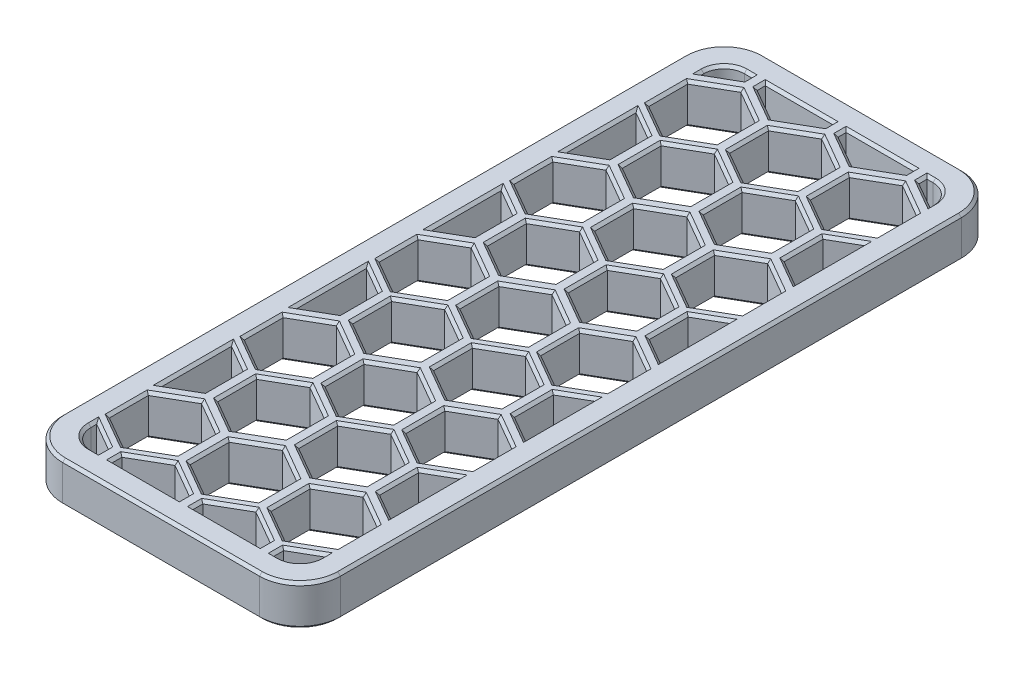
from build123d import *

# Parameters (mm, degrees)
SKETCH1_W               = 137
SKETCH1_H               = 60
BOSS_EXTRUDE1_DEPTH     = 6.5
SKETCH2_W               = 101
SKETCH2_H               = 55.5
CUT_EXTRUDE1_DEPTH      = 1.65
SKETCH3_W               = 87.3
SKETCH3_H               = 55.5
CUT_EXTRUDE2_DEPTH      = 4.1
SKETCH4_W               = 75.4
SKETCH4_H               = 51.7
CUT_EXTRUDE3_DEPTH      = 1.75
FILLET1_R               = 1
SKETCH6_W               = 7.15
SKETCH6_H               = 8
SKETCH6_W_2             = 6.55
CUT_EXTRUDE4_DEPTH      = 2.5
FILLET2_R               = 3
CHAMFER1_SIZE           = 0.5
SKETCH7_W               = 21
SKETCH7_H               = 52.453625608
CUT_EXTRUDE5_DEPTH      = 7.5
FILLET3_R               = 3
FILLET5_R               = 2
CHAMFER3_SIZE           = 1
FILLET6_R               = 1.5
FILLET7_R               = 1
BOSS_EXTRUDE2_DEPTH     = 10
SKETCH9_W               = 73.253326415
SKETCH9_H               = 20.850443035
CUT_EXTRUDE6_DEPTH      = 6.7
CUT_EXTRUDE6_DEPTH_BACK = 132.3
CUT_EXTRUDE7_DEPTH      = 4
BOSS_EXTRUDE3_DEPTH     = 3
CHAMFER4_SIZE           = 0.2
CHAMFER5_SIZE           = 0.2


with BuildPart() as part:
    # Sketch1 → Boss-Extrude1 (new body)
    with BuildSketch(Plane(origin=(0, 0, 0), x_dir=(1, 0, 0), z_dir=(0, 1, 0))):
        Rectangle(SKETCH1_W, SKETCH1_H)
    extrude(amount=BOSS_EXTRUDE1_DEPTH)

    # Sketch2 → Cut-Extrude1 (cut)
    with BuildSketch(Plane(origin=(0, 6.5, 0), x_dir=(1, 0, 0), z_dir=(0, 1, 0))):
        with Locations((14, 0)):
            Rectangle(SKETCH2_W, SKETCH2_H)
    extrude(amount=-CUT_EXTRUDE1_DEPTH, mode=Mode.SUBTRACT)

    # Sketch3 → Cut-Extrude2 (cut)
    with BuildSketch(Plane(origin=(0, 4.85, 0), x_dir=(1, 0, 0), z_dir=(0, 1, 0))):
        with Locations((13.7, 0)):
            Rectangle(SKETCH3_W, SKETCH3_H)
    extrude(amount=-CUT_EXTRUDE2_DEPTH, mode=Mode.SUBTRACT)

    # Sketch4 → Cut-Extrude3 (cut, through all)
    with BuildSketch(Plane(origin=(0, 0.75, 0), x_dir=(1, 0, 0), z_dir=(0, 1, 0))):
        with Locations((17.1, 0)):
            Rectangle(SKETCH4_W, SKETCH4_H)
    extrude(amount=-CUT_EXTRUDE3_DEPTH, mode=Mode.SUBTRACT)

    # Fillet1
    fillet1_edges = [part.edges().sort_by_distance(p)[0] for p in [
        (54.8, 0.375, -25.85),
        (54.8, 0.375, 25.85),
        (-20.6, 0.375, 25.85),
        (-20.6, 0.375, -25.85),
    ]]
    fillet(fillet1_edges, radius=FILLET1_R)

    # Sketch6 → Cut-Extrude4 (cut)
    with BuildSketch(Plane(origin=(0, 4.85, 0), x_dir=(1, 0, 0), z_dir=(0, 1, 0))):
        with Locations((60.925, -23.75)):
            Rectangle(SKETCH6_W, SKETCH6_H)
        with Locations((60.925, 23.75)):
            Rectangle(SKETCH6_W, SKETCH6_H)
        with Locations((-33.225, 23.75)):
            Rectangle(SKETCH6_W_2, SKETCH6_H)
        with Locations((-33.225, -23.75)):
            Rectangle(SKETCH6_W_2, SKETCH6_H)
    extrude(amount=-CUT_EXTRUDE4_DEPTH, mode=Mode.SUBTRACT)

    # Fillet2
    fillet2_edges = [part.edges().sort_by_distance(p)[0] for p in [
        (-29.95, 3.6, 19.75),
        (-29.95, 3.6, -19.75),
        (57.35, 3.6, -19.75),
        (57.35, 3.6, 19.75),
    ]]
    fillet(fillet2_edges, radius=FILLET2_R)

    # Chamfer1
    chamfer1_edges = [part.edges().sort_by_distance(p)[0] for p in [
        (17.1, 0, -25.85),
        (54.8, 0, 0),
        (17.1, 0, 25.85),
        (-20.6, 0, 0),
        (54.507106781, 0, -25.557106781),
        (54.507106781, 0, 25.557106781),
        (-20.307106781, 0, 25.557106781),
        (-20.307106781, 0, -25.557106781),
    ]]
    chamfer(chamfer1_edges, length=CHAMFER1_SIZE)

    # Sketch7 → Cut-Extrude5 (cut, through all)
    with BuildSketch(Plane(origin=(0, 6.5, 0), x_dir=(1, 0, 0), z_dir=(0, 1, 0))):
        with Locations((-52.5, 0)):
            Rectangle(SKETCH7_W, SKETCH7_H)
    extrude(amount=-CUT_EXTRUDE5_DEPTH, mode=Mode.SUBTRACT)

    # Fillet3
    fillet3_edges = [part.edges().sort_by_distance(p)[0] for p in [
        (-42, 3.25, -26.226812804),
        (-42, 3.25, 26.226812804),
        (-63, 3.25, 26.226812804),
        (-63, 3.25, -26.226812804),
    ]]
    fillet(fillet3_edges, radius=FILLET3_R)

    # Fillet5
    fillet5_edges = [part.edges().sort_by_distance(p)[0] for p in [
        (-34.725, 4.85, -19.75),
        (62.425, 4.85, 19.75),
        (62.425, 4.85, -19.75),
        (57.35, 4.85, 0),
        (58.228679656, 4.85, 18.871320344),
        (58.228679656, 4.85, -18.871320344),
        (-34.725, 4.85, 19.75),
        (-29.95, 4.85, 0),
        (-30.828679656, 4.85, -18.871320344),
        (-30.828679656, 4.85, 18.871320344),
    ]]
    fillet(fillet5_edges, radius=FILLET5_R)

    # Chamfer3
    chamfer3_edges = [part.edges().sort_by_distance(p)[0] for p in [
        (-29.95, 2.35, 22.25),
        (-29.95, 2.35, -22.25),
        (57.35, 2.35, -22.25),
        (57.35, 2.35, 22.25),
    ]]
    chamfer(chamfer3_edges, length=CHAMFER3_SIZE)

    # Fillet6
    fillet6_edges = [part.edges().sort_by_distance(p)[0] for p in [
        (68.5, 3.25, 30),
        (-68.5, 3.25, 30),
        (-68.5, 3.25, -30),
        (68.5, 3.25, -30),
    ]]
    fillet(fillet6_edges, radius=FILLET6_R)

    # Fillet7
    fillet7_edges = [part.edges().sort_by_distance(p)[0] for p in [
        (-42, 0, 0),
        (-52.5, 0, 26.226812804),
        (-63, 0, 0),
        (-52.5, 0, -26.226812804),
        (-42.878679656, 0, 25.348133148),
        (-62.121320344, 0, 25.348133148),
        (-62.121320344, 0, -25.348133148),
        (-42.878679656, 0, -25.348133148),
        (68.5, 0, 0),
        (0, 0, 30),
        (-68.5, 0, 0),
        (0, 0, -30),
        (68.060660172, 0, -29.560660172),
        (-68.060660172, 0, -29.560660172),
        (-68.060660172, 0, 29.560660172),
        (68.060660172, 0, 29.560660172),
    ]]
    fillet(fillet7_edges, radius=FILLET7_R)


with BuildPart() as body_2:
    # Sketch8 → Boss-Extrude2 (new body)
    with BuildSketch(Plane.XZ):
        with BuildLine():
            Line((-45, 26.026812804), (-60, 26.026812804))
            ThreePointArc((-60, 26.026812804), (-61.979898987, 25.206711791), (-62.8, 23.226812804))
            Line((-62.8, 23.226812804), (-62.8, -23.226812804))
            ThreePointArc((-62.8, -23.226812804), (-61.979898987, -25.206711791), (-60, -26.026812804))
            Line((-60, -26.026812804), (-45, -26.026812804))
            ThreePointArc((-45, -26.026812804), (-43.020101013, -25.206711791), (-42.2, -23.226812804))
            Line((-42.2, -23.226812804), (-42.2, 23.226812804))
            ThreePointArc((-42.2, 23.226812804), (-43.020101013, 25.206711791), (-45, 26.026812804))
        make_face()
    extrude(amount=BOSS_EXTRUDE2_DEPTH)


with BuildPart() as cut_extrude6_tool:
    # Sketch9 → Cut-Extrude6 (new body, two sides)
    with BuildSketch(Plane.ZY.offset(62.8)) as cut_extrude6_sk:
        with Locations((2.237270989, 3.425221518)):
            Rectangle(SKETCH9_W, SKETCH9_H)
    extrude(amount=CUT_EXTRUDE6_DEPTH)
    extrude(cut_extrude6_sk.sketch, amount=-CUT_EXTRUDE6_DEPTH_BACK)


with BuildPart() as part_1:
    add(part.part)

    # Cut-Extrude6: cut by cut_extrude6_tool
    add(cut_extrude6_tool.part, mode=Mode.SUBTRACT)


with BuildPart() as body_2_1:
    add(body_2.part)

    # Cut-Extrude6: cut by cut_extrude6_tool
    add(cut_extrude6_tool.part, mode=Mode.SUBTRACT)

    # Sketch10 → Cut-Extrude7 (cut, through all)
    with BuildSketch(Plane.XZ.offset(10)):
        with BuildLine():
            Line((-63.94368921, 23.489267463), (-62.8, 22.828958189))
            Line((-62.8, 22.828958189), (-62.8, 23.226812804))
            ThreePointArc((-62.8, 23.226812804), (-61.979898987, 25.206711791), (-60, 26.026812804))
            Line((-60, 26.026812804), (-58.94368921, 26.026812804))
            Line((-58.94368921, 26.026812804), (-58.94368921, 26.376018809))
            Line((-58.94368921, 26.376018809), (-61.44368921, 27.819394482))
            Line((-61.44368921, 27.819394482), (-63.94368921, 26.376018809))
            Line((-63.94368921, 26.376018809), (-63.94368921, 23.489267463))
        make_face()
        Polygon((-57.94368921, 26.376018809), (-57.94368921, 26.026812804), (-52.94368921, 26.026812804), (-52.94368921, 26.376018809), (-55.44368921, 27.819394482), align=None)
        Polygon((-52.94368921, 26.026812804), (-57.94368921, 26.026812804), (-57.94368921, 23.489267463), (-55.44368921, 22.04589179), (-52.94368921, 23.489267463), align=None)
        with BuildLine():
            Line((-62.8, 23.226812804), (-62.8, 22.828958189))
            Line((-62.8, 22.828958189), (-61.44368921, 22.04589179))
            Line((-61.44368921, 22.04589179), (-58.94368921, 23.489267463))
            Line((-58.94368921, 23.489267463), (-58.94368921, 26.026812804))
            Line((-58.94368921, 26.026812804), (-60, 26.026812804))
            ThreePointArc((-60, 26.026812804), (-61.979898987, 25.206711791), (-62.8, 23.226812804))
        make_face()
        Polygon((-46.94368921, 23.489267463), (-46.94368921, 26.026812804), (-51.94368921, 26.026812804), (-51.94368921, 23.489267463), (-49.44368921, 22.04589179), align=None)
        with BuildLine():
            Line((-43.44368921, 22.04589179), (-42.2, 22.76393609))
            Line((-42.2, 22.76393609), (-42.2, 23.226812804))
            ThreePointArc((-42.2, 23.226812804), (-43.020101013, 25.206711791), (-45, 26.026812804))
            Line((-45, 26.026812804), (-45.94368921, 26.026812804))
            Line((-45.94368921, 26.026812804), (-45.94368921, 23.489267463))
            Line((-45.94368921, 23.489267463), (-43.44368921, 22.04589179))
        make_face()
        with BuildLine():
            Line((-42.2, 23.226812804), (-42.2, 22.76393609))
            Line((-42.2, 22.76393609), (-40.94368921, 23.489267463))
            Line((-40.94368921, 23.489267463), (-40.94368921, 26.376018809))
            Line((-40.94368921, 26.376018809), (-43.44368921, 27.819394482))
            Line((-43.44368921, 27.819394482), (-45.94368921, 26.376018809))
            Line((-45.94368921, 26.376018809), (-45.94368921, 26.026812804))
            Line((-45.94368921, 26.026812804), (-45, 26.026812804))
            ThreePointArc((-45, 26.026812804), (-43.020101013, 25.206711791), (-42.2, 23.226812804))
        make_face()
        Polygon((-51.94368921, 26.026812804), (-46.94368921, 26.026812804), (-46.94368921, 26.376018809), (-49.44368921, 27.819394482), (-51.94368921, 26.376018809), align=None)
        Polygon((-48.927948421, 21.438734982), (-48.927948421, 18.551983636), (-46.427948421, 17.108607963), (-43.927948421, 18.551983636), (-43.927948421, 21.438734982), (-46.427948421, 22.882110655), align=None)
        Polygon((-54.927948421, 21.435418911), (-54.927948421, 18.548667565), (-52.427948421, 17.105291892), (-49.927948421, 18.548667565), (-49.927948421, 21.435418911), (-52.427948421, 22.878794584), align=None)
        Polygon((-60.927948421, 21.430714032), (-60.927948421, 18.543962686), (-58.427948421, 17.100587013), (-55.927948421, 18.543962686), (-55.927948421, 21.430714032), (-58.427948421, 22.874089705), align=None)
        Polygon((-62.8, 17.036328082), (-62.8, 12.828958189), (-61.44368921, 12.04589179), (-58.94368921, 13.489267463), (-58.94368921, 16.376018809), (-61.44368921, 17.819394482), align=None)
        Polygon((-63.94368921, 13.489267463), (-62.8, 12.828958189), (-62.8, 17.036328082), (-63.94368921, 16.376018809), align=None)
        Polygon((-57.94368921, 16.376018809), (-57.94368921, 13.489267463), (-55.44368921, 12.04589179), (-52.94368921, 13.489267463), (-52.94368921, 16.376018809), (-55.44368921, 17.819394482), align=None)
        Polygon((-51.94368921, 16.376018809), (-51.94368921, 13.489267463), (-49.44368921, 12.04589179), (-46.94368921, 13.489267463), (-46.94368921, 16.376018809), (-49.44368921, 17.819394482), align=None)
        Polygon((-43.44368921, 12.04589179), (-42.2, 12.76393609), (-42.2, 17.101350181), (-43.44368921, 17.819394482), (-45.94368921, 16.376018809), (-45.94368921, 13.489267463), align=None)
        Polygon((-42.2, 17.101350181), (-42.2, 12.76393609), (-40.94368921, 13.489267463), (-40.94368921, 16.376018809), align=None)
        Polygon((-48.927948421, 11.438734982), (-48.927948421, 8.551983636), (-46.427948421, 7.108607963), (-43.927948421, 8.551983636), (-43.927948421, 11.438734982), (-46.427948421, 12.882110655), align=None)
        Polygon((-54.927948421, 11.435418911), (-54.927948421, 8.548667565), (-52.427948421, 7.105291892), (-49.927948421, 8.548667565), (-49.927948421, 11.435418911), (-52.427948421, 12.878794584), align=None)
        Polygon((-60.927948421, 11.430714032), (-60.927948421, 8.543962686), (-58.427948421, 7.100587013), (-55.927948421, 8.543962686), (-55.927948421, 11.430714032), (-58.427948421, 12.874089705), align=None)
        Polygon((-62.8, 7.036328082), (-62.8, 2.828958189), (-61.44368921, 2.04589179), (-58.94368921, 3.489267463), (-58.94368921, 6.376018809), (-61.44368921, 7.819394482), align=None)
        Polygon((-63.94368921, 3.489267463), (-62.8, 2.828958189), (-62.8, 7.036328082), (-63.94368921, 6.376018809), align=None)
        Polygon((-63.94368921, -6.510732537), (-62.8, -7.171041811), (-62.8, -2.963671918), (-63.94368921, -3.623981191), align=None)
        Polygon((-62.8, -2.963671918), (-62.8, -7.171041811), (-61.44368921, -7.95410821), (-58.94368921, -6.510732537), (-58.94368921, -3.623981191), (-61.44368921, -2.180605518), align=None)
        Polygon((-60.927948421, 1.430714032), (-60.927948421, -1.456037314), (-58.427948421, -2.899412987), (-55.927948421, -1.456037314), (-55.927948421, 1.430714032), (-58.427948421, 2.874089705), align=None)
        Polygon((-57.94368921, 6.376018809), (-57.94368921, 3.489267463), (-55.44368921, 2.04589179), (-52.94368921, 3.489267463), (-52.94368921, 6.376018809), (-55.44368921, 7.819394482), align=None)
        Polygon((-51.94368921, 6.376018809), (-51.94368921, 3.489267463), (-49.44368921, 2.04589179), (-46.94368921, 3.489267463), (-46.94368921, 6.376018809), (-49.44368921, 7.819394482), align=None)
        Polygon((-43.44368921, 2.04589179), (-42.2, 2.76393609), (-42.2, 7.101350181), (-43.44368921, 7.819394482), (-45.94368921, 6.376018809), (-45.94368921, 3.489267463), align=None)
        Polygon((-42.2, 7.101350181), (-42.2, 2.76393609), (-40.94368921, 3.489267463), (-40.94368921, 6.376018809), align=None)
        Polygon((-43.44368921, -7.95410821), (-42.2, -7.23606391), (-42.2, -2.898649819), (-43.44368921, -2.180605518), (-45.94368921, -3.623981191), (-45.94368921, -6.510732537), align=None)
        Polygon((-42.2, -2.898649819), (-42.2, -7.23606391), (-40.94368921, -6.510732537), (-40.94368921, -3.623981191), align=None)
        Polygon((-48.927948421, 1.438734982), (-48.927948421, -1.448016364), (-46.427948421, -2.891392037), (-43.927948421, -1.448016364), (-43.927948421, 1.438734982), (-46.427948421, 2.882110655), align=None)
        Polygon((-54.927948421, 1.435418911), (-54.927948421, -1.451332435), (-52.427948421, -2.894708108), (-49.927948421, -1.451332435), (-49.927948421, 1.435418911), (-52.427948421, 2.878794584), align=None)
        Polygon((-57.94368921, -3.623981191), (-57.94368921, -6.510732537), (-55.44368921, -7.95410821), (-52.94368921, -6.510732537), (-52.94368921, -3.623981191), (-55.44368921, -2.180605518), align=None)
        Polygon((-51.94368921, -3.623981191), (-51.94368921, -6.510732537), (-49.44368921, -7.95410821), (-46.94368921, -6.510732537), (-46.94368921, -3.623981191), (-49.44368921, -2.180605518), align=None)
        Polygon((-48.927948421, -8.561265018), (-48.927948421, -11.448016364), (-46.427948421, -12.891392037), (-43.927948421, -11.448016364), (-43.927948421, -8.561265018), (-46.427948421, -7.117889345), align=None)
        Polygon((-54.927948421, -8.564581089), (-54.927948421, -11.451332435), (-52.427948421, -12.894708108), (-49.927948421, -11.451332435), (-49.927948421, -8.564581089), (-52.427948421, -7.121205416), align=None)
        Polygon((-60.927948421, -8.569285968), (-60.927948421, -11.456037314), (-58.427948421, -12.899412987), (-55.927948421, -11.456037314), (-55.927948421, -8.569285968), (-58.427948421, -7.125910295), align=None)
        Polygon((-62.8, -12.963671918), (-62.8, -17.171041811), (-61.44368921, -17.95410821), (-58.94368921, -16.510732537), (-58.94368921, -13.623981191), (-61.44368921, -12.180605518), align=None)
        Polygon((-63.94368921, -16.510732537), (-62.8, -17.171041811), (-62.8, -12.963671918), (-63.94368921, -13.623981191), align=None)
        with BuildLine():
            Line((-58.94368921, -26.510732537), (-58.94368921, -26.026812804))
            Line((-58.94368921, -26.026812804), (-60, -26.026812804))
            ThreePointArc((-60, -26.026812804), (-61.979898987, -25.206711791), (-62.8, -23.226812804))
            Line((-62.8, -23.226812804), (-62.8, -22.963671918))
            Line((-62.8, -22.963671918), (-63.94368921, -23.623981191))
            Line((-63.94368921, -23.623981191), (-63.94368921, -26.510732537))
            Line((-63.94368921, -26.510732537), (-61.44368921, -27.95410821))
            Line((-61.44368921, -27.95410821), (-58.94368921, -26.510732537))
        make_face()
        with BuildLine():
            Line((-60, -26.026812804), (-58.94368921, -26.026812804))
            Line((-58.94368921, -26.026812804), (-58.94368921, -23.623981191))
            Line((-58.94368921, -23.623981191), (-61.44368921, -22.180605518))
            Line((-61.44368921, -22.180605518), (-62.8, -22.963671918))
            Line((-62.8, -22.963671918), (-62.8, -23.226812804))
            ThreePointArc((-62.8, -23.226812804), (-61.979898987, -25.206711791), (-60, -26.026812804))
        make_face()
        Polygon((-60.927948421, -18.569285968), (-60.927948421, -21.456037314), (-58.427948421, -22.899412987), (-55.927948421, -21.456037314), (-55.927948421, -18.569285968), (-58.427948421, -17.125910295), align=None)
        Polygon((-57.94368921, -26.026812804), (-52.94368921, -26.026812804), (-52.94368921, -23.623981191), (-55.44368921, -22.180605518), (-57.94368921, -23.623981191), align=None)
        Polygon((-57.94368921, -26.510732537), (-55.44368921, -27.95410821), (-52.94368921, -26.510732537), (-52.94368921, -26.026812804), (-57.94368921, -26.026812804), align=None)
        Polygon((-57.94368921, -13.623981191), (-57.94368921, -16.510732537), (-55.44368921, -17.95410821), (-52.94368921, -16.510732537), (-52.94368921, -13.623981191), (-55.44368921, -12.180605518), align=None)
        Polygon((-54.927948421, -18.564581089), (-54.927948421, -21.451332435), (-52.427948421, -22.894708108), (-49.927948421, -21.451332435), (-49.927948421, -18.564581089), (-52.427948421, -17.121205416), align=None)
        Polygon((-51.94368921, -13.623981191), (-51.94368921, -16.510732537), (-49.44368921, -17.95410821), (-46.94368921, -16.510732537), (-46.94368921, -13.623981191), (-49.44368921, -12.180605518), align=None)
        Polygon((-48.927948421, -18.561265018), (-48.927948421, -21.448016364), (-46.427948421, -22.891392037), (-43.927948421, -21.448016364), (-43.927948421, -18.561265018), (-46.427948421, -17.117889345), align=None)
        Polygon((-43.44368921, -17.95410821), (-42.2, -17.23606391), (-42.2, -12.898649819), (-43.44368921, -12.180605518), (-45.94368921, -13.623981191), (-45.94368921, -16.510732537), align=None)
        Polygon((-42.2, -12.898649819), (-42.2, -17.23606391), (-40.94368921, -16.510732537), (-40.94368921, -13.623981191), align=None)
        with BuildLine():
            Line((-45, -26.026812804), (-45.94368921, -26.026812804))
            Line((-45.94368921, -26.026812804), (-45.94368921, -26.510732537))
            Line((-45.94368921, -26.510732537), (-43.44368921, -27.95410821))
            Line((-43.44368921, -27.95410821), (-40.94368921, -26.510732537))
            Line((-40.94368921, -26.510732537), (-40.94368921, -23.623981191))
            Line((-40.94368921, -23.623981191), (-42.2, -22.898649819))
            Line((-42.2, -22.898649819), (-42.2, -23.226812804))
            ThreePointArc((-42.2, -23.226812804), (-43.020101013, -25.206711791), (-45, -26.026812804))
        make_face()
        with BuildLine():
            Line((-45.94368921, -23.623981191), (-45.94368921, -26.026812804))
            Line((-45.94368921, -26.026812804), (-45, -26.026812804))
            ThreePointArc((-45, -26.026812804), (-43.020101013, -25.206711791), (-42.2, -23.226812804))
            Line((-42.2, -23.226812804), (-42.2, -22.898649819))
            Line((-42.2, -22.898649819), (-43.44368921, -22.180605518))
            Line((-43.44368921, -22.180605518), (-45.94368921, -23.623981191))
        make_face()
        Polygon((-51.94368921, -23.623981191), (-51.94368921, -26.026812804), (-46.94368921, -26.026812804), (-46.94368921, -23.623981191), (-49.44368921, -22.180605518), align=None)
        Polygon((-46.94368921, -26.026812804), (-51.94368921, -26.026812804), (-51.94368921, -26.510732537), (-49.44368921, -27.95410821), (-46.94368921, -26.510732537), align=None)
    extrude(amount=-CUT_EXTRUDE7_DEPTH, mode=Mode.SUBTRACT)

    # Sketch12 → Boss-Extrude3 (add)
    with BuildSketch(Plane.XZ.offset(10)):
        with BuildLine():
            Line((-59.8, 26.026812804), (-45.2, 26.026812804))
            ThreePointArc((-45.2, 26.026812804), (-43.078679656, 25.148133148), (-42.2, 23.026812804))
            Line((-42.2, 23.026812804), (-42.2, -23.026812804))
            ThreePointArc((-42.2, -23.026812804), (-43.078679656, -25.148133148), (-45.2, -26.026812804))
            Line((-45.2, -26.026812804), (-59.8, -26.026812804))
            ThreePointArc((-59.8, -26.026812804), (-61.921320344, -25.148133148), (-62.8, -23.026812804))
            Line((-62.8, -23.026812804), (-62.8, 23.026812804))
            ThreePointArc((-62.8, 23.026812804), (-61.921320344, 25.148133148), (-59.8, 26.026812804))
        make_face()
        with BuildLine():
            Line((-59.5, 24.226812804), (-45.5, 24.226812804))
            ThreePointArc((-45.5, 24.226812804), (-44.439339828, 23.787472976), (-44, 22.726812804))
            Line((-44, 22.726812804), (-44, -22.726812804))
            ThreePointArc((-44, -22.726812804), (-44.439339828, -23.787472976), (-45.5, -24.226812804))
            Line((-45.5, -24.226812804), (-59.5, -24.226812804))
            ThreePointArc((-59.5, -24.226812804), (-60.560660172, -23.787472976), (-61, -22.726812804))
            Line((-61, -22.726812804), (-61, 22.726812804))
            ThreePointArc((-61, 22.726812804), (-60.560660172, 23.787472976), (-59.5, 24.226812804))
        make_face(mode=Mode.SUBTRACT)
    extrude(amount=-BOSS_EXTRUDE3_DEPTH)

    # Chamfer4
    chamfer4_edges = [body_2_1.edges().sort_by_distance(p)[0] for p in [
        (-45.21397421, -10, 2.181222318),
        (-44.971844605, -10, -3.062886447),
        (-44.971844605, -10, 6.937113553),
        (-58.94368921, -10, -23.925396998),
        (-52.94368921, -10, -23.925396998),
        (-59.971844605, -10, -17.104338331),
        (-45.21397421, -10, -7.818777682),
        (-59.971844605, -10, 12.895661669),
        (-59.971844605, -10, 22.895661669),
        (-45.94368921, -10, 23.858040133),
        (-45.21397421, -10, 22.181222318),
        (-51.94368921, -10, 23.858040133),
        (-45.21397421, -10, 12.181222318),
        (-44.971844605, -10, 16.937113553),
        (-59.971844605, -10, -7.104338331),
        (-59.971844605, -10, 2.895661669),
        (-46.94368921, -10, -23.925396998),
        (-44.971844605, -10, -23.062886447),
        (-44.971844605, -10, -13.062886447),
        (-45.21397421, -10, -17.818777682),
        (-57.94368921, -10, 23.858040133),
        (-55.44368921, -10, 24.226812804),
        (-49.44368921, -10, 24.226812804),
        (-45.721844605, -10, 24.226812804),
        (-59.221844605, -10, 24.226812804),
        (-45.721844605, -10, -24.226812804),
        (-49.44368921, -10, -24.226812804),
        (-55.44368921, -10, -24.226812804),
        (-59.221844605, -10, -24.226812804),
        (-61, -10, 4.932643136),
        (-61, -10, -5.067356864),
        (-61, -10, 22.514434339),
        (-61, -10, 14.932643136),
        (-61, -10, -15.067356864),
        (-61, -10, -22.581791204),
        (-43.078679656, -10, -25.148133148),
        (-43.078679656, -10, 25.148133148),
        (-61.921320344, -10, 25.148133148),
        (-61.921320344, -10, -25.148133148),
        (-44, -10, -20.004640691),
        (-44, -10, -15.067356864),
        (-44, -10, -22.614302253),
        (-44, -10, 14.932643136),
        (-44, -10, 9.995359309),
        (-44, -10, 19.995359309),
        (-44, -10, 22.546945389),
        (-44, -10, -10.004640691),
        (-44, -10, 4.932643136),
        (-44, -10, -5.067356864),
        (-44, -10, -0.004640691),
        (-44.439339828, -10, -23.787472976),
        (-44.439339828, -10, 23.787472976),
        (-60.560660172, -10, 23.787472976),
        (-60.560660172, -10, -23.787472976),
        (-62.8, -10, 0),
        (-52.5, -10, -26.026812804),
        (-42.2, -10, 0),
        (-52.5, -10, 26.026812804),
        (-48.927948421, -10, -0.004640691),
        (-47.677948421, -10, -2.169704201),
        (-45.21397421, -10, -2.1905037),
        (-47.677948421, -10, 2.160422818),
        (-54.927948421, -10, -0.007956762),
        (-53.677948421, -10, -2.173020271),
        (-51.177948421, -10, -2.173020271),
        (-49.927948421, -10, -0.007956762),
        (-51.177948421, -10, 2.157106748),
        (-53.677948421, -10, 2.157106748),
        (-57.94368921, -10, -5.067356864),
        (-56.69368921, -10, -7.232420374),
        (-54.19368921, -10, -7.232420374),
        (-52.94368921, -10, -5.067356864),
        (-54.19368921, -10, -2.902293355),
        (-56.69368921, -10, -2.902293355),
        (-51.94368921, -10, -5.067356864),
        (-50.69368921, -10, -7.232420374),
        (-48.19368921, -10, -7.232420374),
        (-46.94368921, -10, -5.067356864),
        (-48.19368921, -10, -2.902293355),
        (-50.69368921, -10, -2.902293355),
        (-45.94368921, -10, -5.067356864),
        (-44.971844605, -10, -7.071827282),
        (-45.94368921, -10, 4.932643136),
        (-44.971844605, -10, 2.928172718),
        (-51.94368921, -10, 4.932643136),
        (-50.69368921, -10, 2.767579626),
        (-48.19368921, -10, 2.767579626),
        (-46.94368921, -10, 4.932643136),
        (-48.19368921, -10, 7.097706645),
        (-50.69368921, -10, 7.097706645),
        (-57.94368921, -10, 4.932643136),
        (-56.69368921, -10, 2.767579626),
        (-54.19368921, -10, 2.767579626),
        (-52.94368921, -10, 4.932643136),
        (-54.19368921, -10, 7.097706645),
        (-56.69368921, -10, 7.097706645),
        (-60.927948421, -10, -20.012661641),
        (-59.677948421, -10, -22.17772515),
        (-57.177948421, -10, -22.17772515),
        (-55.927948421, -10, -20.012661641),
        (-57.177948421, -10, -17.847598131),
        (-59.677948421, -10, -17.847598131),
        (-59.971844605, -10, -23.030375397),
        (-57.94368921, -10, -23.925396998),
        (-54.19368921, -10, -22.902293355),
        (-56.69368921, -10, -22.902293355),
        (-57.94368921, -10, -15.067356864),
        (-56.69368921, -10, -17.232420374),
        (-54.19368921, -10, -17.232420374),
        (-52.94368921, -10, -15.067356864),
        (-54.19368921, -10, -12.902293355),
        (-56.69368921, -10, -12.902293355),
        (-60.927948421, -10, -10.012661641),
        (-59.677948421, -10, -12.17772515),
        (-57.177948421, -10, -12.17772515),
        (-55.927948421, -10, -10.012661641),
        (-57.177948421, -10, -7.847598131),
        (-59.677948421, -10, -7.847598131),
        (-58.94368921, -10, -15.067356864),
        (-59.971844605, -10, -13.030375397),
        (-54.927948421, -10, -10.007956762),
        (-53.677948421, -10, -12.173020271),
        (-51.177948421, -10, -12.173020271),
        (-49.927948421, -10, -10.007956762),
        (-51.177948421, -10, -7.842893252),
        (-53.677948421, -10, -7.842893252),
        (-48.927948421, -10, -10.004640691),
        (-47.677948421, -10, -12.169704201),
        (-45.21397421, -10, -12.1905037),
        (-47.677948421, -10, -7.839577182),
        (-54.927948421, -10, 19.992043238),
        (-53.677948421, -10, 17.826979729),
        (-51.177948421, -10, 17.826979729),
        (-49.927948421, -10, 19.992043238),
        (-51.177948421, -10, 22.157106748),
        (-53.677948421, -10, 22.157106748),
        (-60.927948421, -10, 19.987338359),
        (-59.677948421, -10, 17.82227485),
        (-57.177948421, -10, 17.82227485),
        (-55.927948421, -10, 19.987338359),
        (-57.177948421, -10, 22.152401869),
        (-59.677948421, -10, 22.152401869),
        (-58.94368921, -10, 14.932643136),
        (-59.971844605, -10, 16.969624603),
        (-57.94368921, -10, 14.932643136),
        (-56.69368921, -10, 12.767579626),
        (-54.19368921, -10, 12.767579626),
        (-52.94368921, -10, 14.932643136),
        (-54.19368921, -10, 17.097706645),
        (-56.69368921, -10, 17.097706645),
        (-58.94368921, -10, 23.858040133),
        (-44.971844605, -10, 22.928172718),
        (-48.927948421, -10, 19.995359309),
        (-47.677948421, -10, 17.830295799),
        (-45.21397421, -10, 17.8094963),
        (-47.677948421, -10, 22.160422818),
        (-46.94368921, -10, 23.858040133),
        (-50.69368921, -10, 22.767579626),
        (-48.19368921, -10, 22.767579626),
        (-54.927948421, -10, 9.992043238),
        (-53.677948421, -10, 7.826979729),
        (-51.177948421, -10, 7.826979729),
        (-49.927948421, -10, 9.992043238),
        (-51.177948421, -10, 12.157106748),
        (-53.677948421, -10, 12.157106748),
        (-48.927948421, -10, 9.995359309),
        (-47.677948421, -10, 7.830295799),
        (-45.21397421, -10, 7.8094963),
        (-47.677948421, -10, 12.160422818),
        (-45.94368921, -10, 14.932643136),
        (-44.971844605, -10, 12.928172718),
        (-51.94368921, -10, 14.932643136),
        (-50.69368921, -10, 12.767579626),
        (-48.19368921, -10, 12.767579626),
        (-46.94368921, -10, 14.932643136),
        (-48.19368921, -10, 17.097706645),
        (-50.69368921, -10, 17.097706645),
        (-58.94368921, -10, -5.067356864),
        (-59.971844605, -10, -3.030375397),
        (-60.927948421, -10, -0.012661641),
        (-59.677948421, -10, -2.17772515),
        (-57.177948421, -10, -2.17772515),
        (-55.927948421, -10, -0.012661641),
        (-57.177948421, -10, 2.152401869),
        (-59.677948421, -10, 2.152401869),
        (-60.927948421, -10, 9.987338359),
        (-59.677948421, -10, 7.82227485),
        (-57.177948421, -10, 7.82227485),
        (-55.927948421, -10, 9.987338359),
        (-57.177948421, -10, 12.152401869),
        (-59.677948421, -10, 12.152401869),
        (-58.94368921, -10, 4.932643136),
        (-59.971844605, -10, 6.969624603),
        (-51.94368921, -10, -23.925396998),
        (-48.19368921, -10, -22.902293355),
        (-50.69368921, -10, -22.902293355),
        (-45.94368921, -10, -23.925396998),
        (-51.94368921, -10, -15.067356864),
        (-50.69368921, -10, -17.232420374),
        (-48.19368921, -10, -17.232420374),
        (-46.94368921, -10, -15.067356864),
        (-48.19368921, -10, -12.902293355),
        (-50.69368921, -10, -12.902293355),
        (-54.927948421, -10, -20.007956762),
        (-53.677948421, -10, -22.173020271),
        (-51.177948421, -10, -22.173020271),
        (-49.927948421, -10, -20.007956762),
        (-51.177948421, -10, -17.842893252),
        (-53.677948421, -10, -17.842893252),
        (-45.94368921, -10, -15.067356864),
        (-44.971844605, -10, -17.071827282),
        (-48.927948421, -10, -20.004640691),
        (-47.677948421, -10, -22.169704201),
        (-45.21397421, -10, -22.1905037),
        (-47.677948421, -10, -17.839577182),
        (-52.94368921, -10, 23.858040133),
        (-56.69368921, -10, 22.767579626),
        (-54.19368921, -10, 22.767579626),
    ]]
    chamfer(chamfer4_edges, length=CHAMFER4_SIZE)

    # Chamfer5
    chamfer5_edges = [body_2_1.edges().sort_by_distance(p)[0] for p in [
        (-45.21397421, -7, 2.181222318),
        (-44.971844605, -7, -3.062886447),
        (-44.971844605, -7, 6.937113553),
        (-58.94368921, -7, -23.925396998),
        (-52.94368921, -7, -23.925396998),
        (-59.971844605, -7, -17.104338331),
        (-45.21397421, -7, -7.818777682),
        (-59.971844605, -7, 12.895661669),
        (-59.971844605, -7, 22.895661669),
        (-45.94368921, -7, 23.858040133),
        (-45.21397421, -7, 22.181222318),
        (-51.94368921, -7, 23.858040133),
        (-45.21397421, -7, 12.181222318),
        (-44.971844605, -7, 16.937113553),
        (-59.971844605, -7, -7.104338331),
        (-59.971844605, -7, 2.895661669),
        (-46.94368921, -7, -23.925396998),
        (-44.971844605, -7, -23.062886447),
        (-44.971844605, -7, -13.062886447),
        (-45.21397421, -7, -17.818777682),
        (-57.94368921, -7, 23.858040133),
        (-55.44368921, -7, 24.226812804),
        (-49.44368921, -7, 24.226812804),
        (-45.721844605, -7, 24.226812804),
        (-59.221844605, -7, 24.226812804),
        (-45.721844605, -7, -24.226812804),
        (-49.44368921, -7, -24.226812804),
        (-55.44368921, -7, -24.226812804),
        (-59.221844605, -7, -24.226812804),
        (-61, -7, 4.932643136),
        (-61, -7, -5.067356864),
        (-61, -7, 22.514434339),
        (-61, -7, 14.932643136),
        (-61, -7, -15.067356864),
        (-61, -7, -22.581791204),
        (-44, -7, -20.004640691),
        (-44, -7, -15.067356864),
        (-44, -7, -22.614302253),
        (-44, -7, 14.932643136),
        (-44, -7, 9.995359309),
        (-44, -7, 19.995359309),
        (-44, -7, 22.546945389),
        (-44, -7, -10.004640691),
        (-44, -7, 4.932643136),
        (-44, -7, -5.067356864),
        (-44, -7, -0.004640691),
        (-43.078679656, -7, -25.148133148),
        (-43.078679656, -7, 25.148133148),
        (-61.921320344, -7, 25.148133148),
        (-61.921320344, -7, -25.148133148),
        (-44.439339828, -7, -23.787472976),
        (-44.439339828, -7, 23.787472976),
        (-60.560660172, -7, 23.787472976),
        (-60.560660172, -7, -23.787472976),
        (-48.927948421, -7, -0.004640691),
        (-47.677948421, -7, 2.160422818),
        (-45.21397421, -7, -2.1905037),
        (-47.677948421, -7, -2.169704201),
        (-54.927948421, -7, -0.007956762),
        (-53.677948421, -7, 2.157106748),
        (-51.177948421, -7, 2.157106748),
        (-49.927948421, -7, -0.007956762),
        (-51.177948421, -7, -2.173020271),
        (-53.677948421, -7, -2.173020271),
        (-57.94368921, -7, -5.067356864),
        (-56.69368921, -7, -2.902293355),
        (-54.19368921, -7, -2.902293355),
        (-52.94368921, -7, -5.067356864),
        (-54.19368921, -7, -7.232420374),
        (-56.69368921, -7, -7.232420374),
        (-51.94368921, -7, -5.067356864),
        (-50.69368921, -7, -2.902293355),
        (-48.19368921, -7, -2.902293355),
        (-46.94368921, -7, -5.067356864),
        (-48.19368921, -7, -7.232420374),
        (-50.69368921, -7, -7.232420374),
        (-45.94368921, -7, -5.067356864),
        (-44.971844605, -7, -7.071827282),
        (-45.94368921, -7, 4.932643136),
        (-44.971844605, -7, 2.928172718),
        (-51.94368921, -7, 4.932643136),
        (-50.69368921, -7, 7.097706645),
        (-48.19368921, -7, 7.097706645),
        (-46.94368921, -7, 4.932643136),
        (-48.19368921, -7, 2.767579626),
        (-50.69368921, -7, 2.767579626),
        (-57.94368921, -7, 4.932643136),
        (-56.69368921, -7, 7.097706645),
        (-54.19368921, -7, 7.097706645),
        (-52.94368921, -7, 4.932643136),
        (-54.19368921, -7, 2.767579626),
        (-56.69368921, -7, 2.767579626),
        (-60.927948421, -7, -20.012661641),
        (-59.677948421, -7, -17.847598131),
        (-57.177948421, -7, -17.847598131),
        (-55.927948421, -7, -20.012661641),
        (-57.177948421, -7, -22.17772515),
        (-59.677948421, -7, -22.17772515),
        (-59.971844605, -7, -23.030375397),
        (-57.94368921, -7, -23.925396998),
        (-56.69368921, -7, -22.902293355),
        (-54.19368921, -7, -22.902293355),
        (-57.94368921, -7, -15.067356864),
        (-56.69368921, -7, -12.902293355),
        (-54.19368921, -7, -12.902293355),
        (-52.94368921, -7, -15.067356864),
        (-54.19368921, -7, -17.232420374),
        (-56.69368921, -7, -17.232420374),
        (-60.927948421, -7, -10.012661641),
        (-59.677948421, -7, -7.847598131),
        (-57.177948421, -7, -7.847598131),
        (-55.927948421, -7, -10.012661641),
        (-57.177948421, -7, -12.17772515),
        (-59.677948421, -7, -12.17772515),
        (-59.971844605, -7, -13.030375397),
        (-58.94368921, -7, -15.067356864),
        (-54.927948421, -7, -10.007956762),
        (-53.677948421, -7, -7.842893252),
        (-51.177948421, -7, -7.842893252),
        (-49.927948421, -7, -10.007956762),
        (-51.177948421, -7, -12.173020271),
        (-53.677948421, -7, -12.173020271),
        (-48.927948421, -7, -10.004640691),
        (-47.677948421, -7, -7.839577182),
        (-45.21397421, -7, -12.1905037),
        (-47.677948421, -7, -12.169704201),
        (-54.927948421, -7, 19.992043238),
        (-53.677948421, -7, 22.157106748),
        (-51.177948421, -7, 22.157106748),
        (-49.927948421, -7, 19.992043238),
        (-51.177948421, -7, 17.826979729),
        (-53.677948421, -7, 17.826979729),
        (-60.927948421, -7, 19.987338359),
        (-59.677948421, -7, 22.152401869),
        (-57.177948421, -7, 22.152401869),
        (-55.927948421, -7, 19.987338359),
        (-57.177948421, -7, 17.82227485),
        (-59.677948421, -7, 17.82227485),
        (-59.971844605, -7, 16.969624603),
        (-58.94368921, -7, 14.932643136),
        (-57.94368921, -7, 14.932643136),
        (-56.69368921, -7, 17.097706645),
        (-54.19368921, -7, 17.097706645),
        (-52.94368921, -7, 14.932643136),
        (-54.19368921, -7, 12.767579626),
        (-56.69368921, -7, 12.767579626),
        (-58.94368921, -7, 23.858040133),
        (-44.971844605, -7, 22.928172718),
        (-48.927948421, -7, 19.995359309),
        (-47.677948421, -7, 22.160422818),
        (-45.21397421, -7, 17.8094963),
        (-47.677948421, -7, 17.830295799),
        (-46.94368921, -7, 23.858040133),
        (-48.19368921, -7, 22.767579626),
        (-50.69368921, -7, 22.767579626),
        (-54.927948421, -7, 9.992043238),
        (-53.677948421, -7, 12.157106748),
        (-51.177948421, -7, 12.157106748),
        (-49.927948421, -7, 9.992043238),
        (-51.177948421, -7, 7.826979729),
        (-53.677948421, -7, 7.826979729),
        (-48.927948421, -7, 9.995359309),
        (-47.677948421, -7, 12.160422818),
        (-45.21397421, -7, 7.8094963),
        (-47.677948421, -7, 7.830295799),
        (-45.94368921, -7, 14.932643136),
        (-44.971844605, -7, 12.928172718),
        (-51.94368921, -7, 14.932643136),
        (-50.69368921, -7, 17.097706645),
        (-48.19368921, -7, 17.097706645),
        (-46.94368921, -7, 14.932643136),
        (-48.19368921, -7, 12.767579626),
        (-50.69368921, -7, 12.767579626),
        (-59.971844605, -7, -3.030375397),
        (-58.94368921, -7, -5.067356864),
        (-52.5, -7, 26.026812804),
        (-60.927948421, -7, -0.012661641),
        (-59.677948421, -7, 2.152401869),
        (-57.177948421, -7, 2.152401869),
        (-55.927948421, -7, -0.012661641),
        (-57.177948421, -7, -2.17772515),
        (-59.677948421, -7, -2.17772515),
        (-60.927948421, -7, 9.987338359),
        (-59.677948421, -7, 12.152401869),
        (-57.177948421, -7, 12.152401869),
        (-55.927948421, -7, 9.987338359),
        (-57.177948421, -7, 7.82227485),
        (-59.677948421, -7, 7.82227485),
        (-42.2, -7, 0),
        (-59.971844605, -7, 6.969624603),
        (-58.94368921, -7, 4.932643136),
        (-51.94368921, -7, -23.925396998),
        (-50.69368921, -7, -22.902293355),
        (-48.19368921, -7, -22.902293355),
        (-45.94368921, -7, -23.925396998),
        (-52.5, -7, -26.026812804),
        (-51.94368921, -7, -15.067356864),
        (-50.69368921, -7, -12.902293355),
        (-48.19368921, -7, -12.902293355),
        (-46.94368921, -7, -15.067356864),
        (-48.19368921, -7, -17.232420374),
        (-50.69368921, -7, -17.232420374),
        (-62.8, -7, 0),
        (-54.927948421, -7, -20.007956762),
        (-53.677948421, -7, -17.842893252),
        (-51.177948421, -7, -17.842893252),
        (-49.927948421, -7, -20.007956762),
        (-51.177948421, -7, -22.173020271),
        (-53.677948421, -7, -22.173020271),
        (-45.94368921, -7, -15.067356864),
        (-44.971844605, -7, -17.071827282),
        (-48.927948421, -7, -20.004640691),
        (-47.677948421, -7, -17.839577182),
        (-45.21397421, -7, -22.1905037),
        (-47.677948421, -7, -22.169704201),
        (-52.94368921, -7, 23.858040133),
        (-54.19368921, -7, 22.767579626),
        (-56.69368921, -7, 22.767579626),
    ]]
    chamfer(chamfer5_edges, length=CHAMFER5_SIZE)


solid = body_2_1.part
